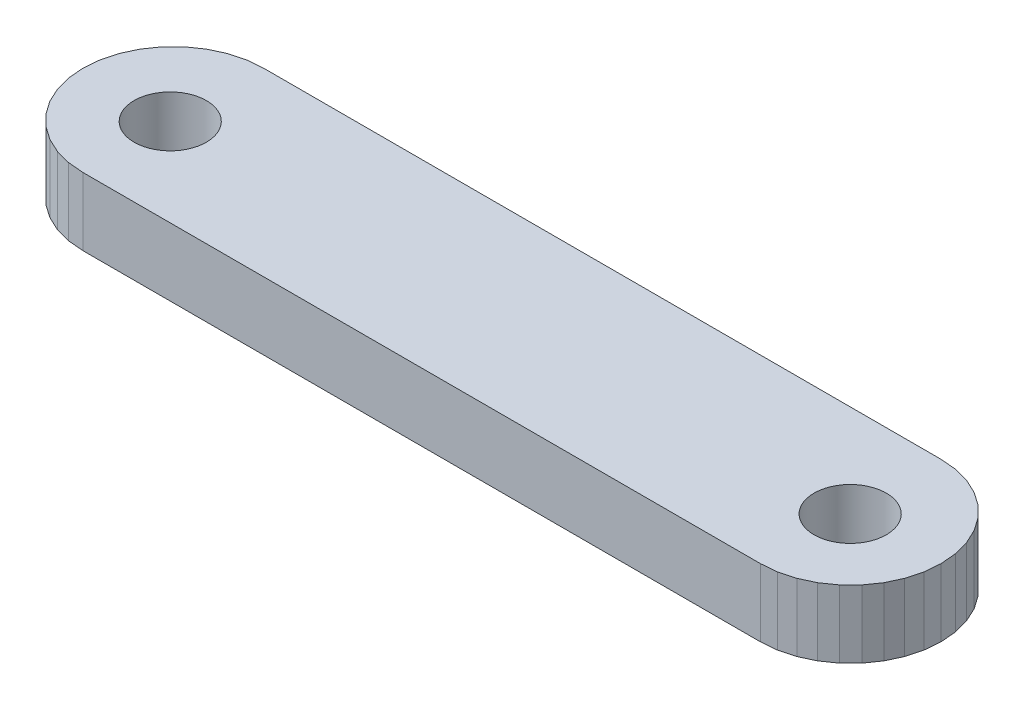
from build123d import *

# Parameters (mm, degrees)
BOSS_EXTRUDE1_DEPTH  = 3.000000026
SKETCH2_R            = 2.767129072
SKETCH2_R_2          = 3.006829377
BOSS_EXTRUDE2_DEPTH  = 3
M3_CLEARANCE_HOLE1_D = 3.2


with BuildPart() as part:
    # Sketch1 → Boss-Extrude1 (new body)
    with BuildSketch(Plane.XZ):
        Polygon((3.305407241, 0.060769264), (3.999999724, 0), (34.000001848, 0), (34.694589674, 0.060769264), (35.368077457, 0.241229776), (35.99999845, 0.535898609), (36.571152508, 0.935822492), (37.064179778, 1.428849762), (37.464100868, 2.000000095), (37.758767605, 2.631919459), (37.939228117, 3.305407474), (37.999998778, 4.00000019), (37.939228117, 4.694593139), (37.758767605, 5.368080921), (37.464100868, 6.000000052), (37.064179778, 6.571150385), (36.571152508, 7.064177655), (35.99999845, 7.464101538), (35.368077457, 7.758770604), (34.694589674, 7.939230651), (34.000001848, 8.00000038), (3.999999724, 8.00000038), (3.305407241, 7.939230651), (2.631919459, 7.758770604), (1.999998465, 7.464101538), (1.428848132, 7.064177655), (0.935820863, 6.571150385), (0.535897911, 6.000000052), (0.241229311, 5.368080921), (0.060768798, 4.694593139), (0, 4.00000019), (0.060768798, 3.305407474), (0.241229311, 2.631919459), (0.535897911, 2.000000095), (0.935820863, 1.428849762), (1.428848132, 0.935822492), (1.999998465, 0.535898609), (2.631919459, 0.241229776), align=None)
        Polygon((32.391306013, 2.650146373), (32.181344926, 2.950000111), (32.026644796, 3.281757934), (31.931903213, 3.635338973), (31.899999827, 4.00000019), (31.931903213, 4.364661407), (32.026644796, 4.718242679), (32.181344926, 5.050000269), (32.391306013, 5.349854007), (32.650146633, 5.608693697), (32.949998975, 5.818653386), (33.281758428, 5.973354913), (33.635336906, 6.068096496), (34.000001848, 6.099999882), (34.364659339, 6.068096496), (34.718241543, 5.973354913), (35.04999727, 5.818653386), (35.349853337, 5.608693697), (35.608693957, 5.349854007), (35.818651319, 5.050000269), (35.973355174, 4.718242679), (36.068096757, 4.364661407), (36.100000143, 4.00000019), (36.068096757, 3.635338973), (35.973355174, 3.281757934), (35.818651319, 2.950000111), (35.608693957, 2.650146373), (35.349853337, 2.391306916), (35.04999727, 2.181346994), (34.718241543, 2.0266457), (34.364659339, 1.931903884), (34.000001848, 1.900000265), (33.635336906, 1.931903884), (33.281758428, 2.0266457), (32.949998975, 2.181346994), (32.650146633, 2.391306916), align=None, mode=Mode.SUBTRACT)
        Polygon((5.685296841, 2.58586742), (5.414132029, 2.314702375), (5.099999718, 2.094744239), (4.752444103, 1.932676416), (4.38202545, 1.833423041), (3.999999724, 1.800000202), (3.617973067, 1.833423041), (3.247555345, 1.932676416), (2.899998799, 2.094744239), (2.58586742, 2.314702375), (2.314701444, 2.58586742), (2.094743773, 2.900000196), (1.932675019, 3.247555811), (1.833422109, 3.617974231), (1.799998805, 4.00000019), (1.833422109, 4.382026382), (1.932675019, 4.752444569), (2.094743773, 5.100000184), (2.314701444, 5.41413296), (2.58586742, 5.685297772), (2.899998799, 5.905256141), (3.247555345, 6.067323964), (3.617973067, 6.166577339), (3.999999724, 6.200000178), (4.38202545, 6.166577339), (4.752444103, 6.067323964), (5.099999718, 5.905256141), (5.414132029, 5.685297772), (5.685296841, 5.41413296), (5.905255675, 5.100000184), (6.067323498, 4.752444569), (6.166576408, 4.382026382), (6.199999712, 4.00000019), (6.166576408, 3.617974231), (6.067323498, 3.247555811), (5.905255675, 2.900000196), align=None, mode=Mode.SUBTRACT)
    extrude(amount=-BOSS_EXTRUDE1_DEPTH)

    # Sketch2 → Boss-Extrude2 (add)
    with BuildSketch(Plane(origin=(0, 3.000000026, 0), x_dir=(1, 0, 0), z_dir=(0, 1, 0))):
        with Locations((3.930419847, -4.196730993)):
            Circle(SKETCH2_R)
        with Locations((34.148271252, -4.196730993)):
            Circle(SKETCH2_R_2)
    extrude(amount=-BOSS_EXTRUDE2_DEPTH)

    # M3 Clearance Hole1 (through all)
    with Locations(Plane(origin=(0, 3.000000026, 0), x_dir=(1, 0, 0), z_dir=(0, 1, 0))):
        with Locations((3.974411457, -4.108268671), (34.083612048, -4.108268671)):
            Hole(M3_CLEARANCE_HOLE1_D / 2)


solid = part.part
